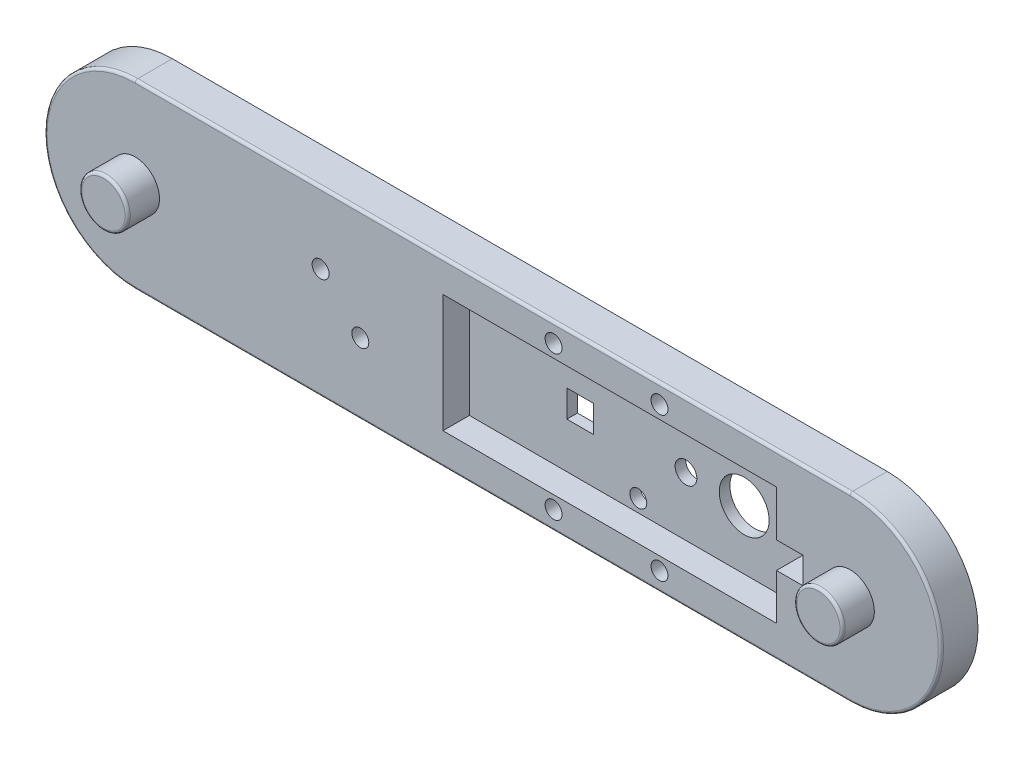
from build123d import *

# Parameters (mm, degrees)
SKETCH6_R              = 1.6
SKETCH6_R_2            = 2.575
SKETCH6_W              = 5
SKETCH6_H              = 5
SKETCH6_H_2            = 5.1
SKETCH6_R_3            = 2.05
SKETCH6_R_4            = 4.707512696
BOSS_EXTRUDE4_DEPTH    = 2
SKETCH7_R              = 1.6
SKETCH7_R_2            = 2.575
BOSS_EXTRUDE5_DEPTH    = 5
SKETCH8_R              = 1.6
MIDSECTION_HOLES_DEPTH = 8
SKETCH12_R             = 4.575
BOSS_EXTRUDE6_DEPTH    = 6
SKETCH13_R             = 2.575
CUT_EXTRUDE4_DEPTH     = 4
FILLET1_R              = 0.5


with BuildPart() as part:
    # Sketch6 → Boss-Extrude4 (new body)
    with BuildSketch(Plane.XY):
        with BuildLine():
            Line((25, 17.15), (-110, 17.15))
            ThreePointArc((-110, 17.15), (-127.15, 0), (-110, -17.15))
            Line((-110, -17.15), (25, -17.15))
            ThreePointArc((25, -17.15), (42.15, 0), (25, 17.15))
        make_face()
        with Locations((-31, -13.6)):
            Circle(SKETCH6_R, mode=Mode.SUBTRACT)
        with Locations((-11, -13.6)):
            Circle(SKETCH6_R, mode=Mode.SUBTRACT)
        with Locations((-110, 0)):
            Circle(SKETCH6_R_2, mode=Mode.SUBTRACT)
        with Locations((13.6, 0)):
            Rectangle(SKETCH6_W, SKETCH6_H, mode=Mode.SUBTRACT)
        with Locations((25, 0)):
            Circle(SKETCH6_R_2, mode=Mode.SUBTRACT)
        with Locations((-31, 13.6)):
            Circle(SKETCH6_R, mode=Mode.SUBTRACT)
        with Locations((-11, 13.6)):
            Circle(SKETCH6_R, mode=Mode.SUBTRACT)
        with Locations((-31, 0)):
            Rectangle(SKETCH6_W, SKETCH6_H_2, mode=Mode.SUBTRACT)
        with Locations((-11, 0)):
            Circle(SKETCH6_R_3, mode=Mode.SUBTRACT)
        Circle(SKETCH6_R_4, mode=Mode.SUBTRACT)
        with Locations((-20, 8.75)):
            Circle(SKETCH6_R, mode=Mode.SUBTRACT)
        with Locations((-20, -8.75)):
            Circle(SKETCH6_R, mode=Mode.SUBTRACT)
    extrude(amount=BOSS_EXTRUDE4_DEPTH)

    # Sketch7 → Boss-Extrude5 (add)
    with BuildSketch(Plane.XY.offset(2)):
        with BuildLine():
            Line((25, 17.15), (-110, 17.15))
            ThreePointArc((-110, 17.15), (-127.15, 0), (-110, -17.15))
            Line((-110, -17.15), (25, -17.15))
            ThreePointArc((25, -17.15), (42.15, 0), (25, 17.15))
        make_face()
        with Locations((-31, -13.6)):
            Circle(SKETCH7_R, mode=Mode.SUBTRACT)
        with Locations((-11, -13.6)):
            Circle(SKETCH7_R, mode=Mode.SUBTRACT)
        with Locations((-110, 0)):
            Circle(SKETCH7_R_2, mode=Mode.SUBTRACT)
        Polygon((-51.9, -11.15), (-51.9, 11.15), (11.1, 11.15), (11.1, 2.5), (16.1, 2.5), (16.1, -2.5), (11.1, -2.5), (11.1, -11.15), align=None, mode=Mode.SUBTRACT)
        with Locations((25, 0)):
            Circle(SKETCH7_R_2, mode=Mode.SUBTRACT)
        with Locations((-31, 13.6)):
            Circle(SKETCH7_R, mode=Mode.SUBTRACT)
        with Locations((-11, 13.6)):
            Circle(SKETCH7_R, mode=Mode.SUBTRACT)
    extrude(amount=BOSS_EXTRUDE5_DEPTH)

    # Sketch8 → midsection_holes (cut, through all)
    with BuildSketch(Plane.XY.offset(7)):
        with Locations((-75, 3.75)):
            Circle(SKETCH8_R)
        with Locations((-67.5, -3.75)):
            Circle(SKETCH8_R)
    extrude(amount=-MIDSECTION_HOLES_DEPTH, mode=Mode.SUBTRACT)

    # Sketch12 → Boss-Extrude6 (add)
    with BuildSketch(Plane.XY.offset(7)):
        with Locations((-110, 0)):
            Circle(SKETCH12_R)
        with Locations((25, 0)):
            Circle(SKETCH12_R)
    extrude(amount=BOSS_EXTRUDE6_DEPTH)

    # Sketch13 → Cut-Extrude4 (cut)
    with BuildSketch(Plane(origin=(0, 0, 7), x_dir=(-1, 0, 0), z_dir=(0, 0, -1))):
        with Locations((-25, 0)):
            Circle(SKETCH13_R)
        with Locations((110, 0)):
            Circle(SKETCH13_R)
    extrude(amount=-CUT_EXTRUDE4_DEPTH, mode=Mode.SUBTRACT)

    # Fillet1
    fillet1_edges = [part.edges().sort_by_distance(p)[0] for p in [
        (-114.575, 0, 13),
        (20.425, 0, 13),
        (-127.15, 0, 7),
        (-42.5, -17.15, 7),
        (42.15, 0, 7),
        (-42.5, 17.15, 7),
    ]]
    fillet(fillet1_edges, radius=FILLET1_R)


solid = part.part
